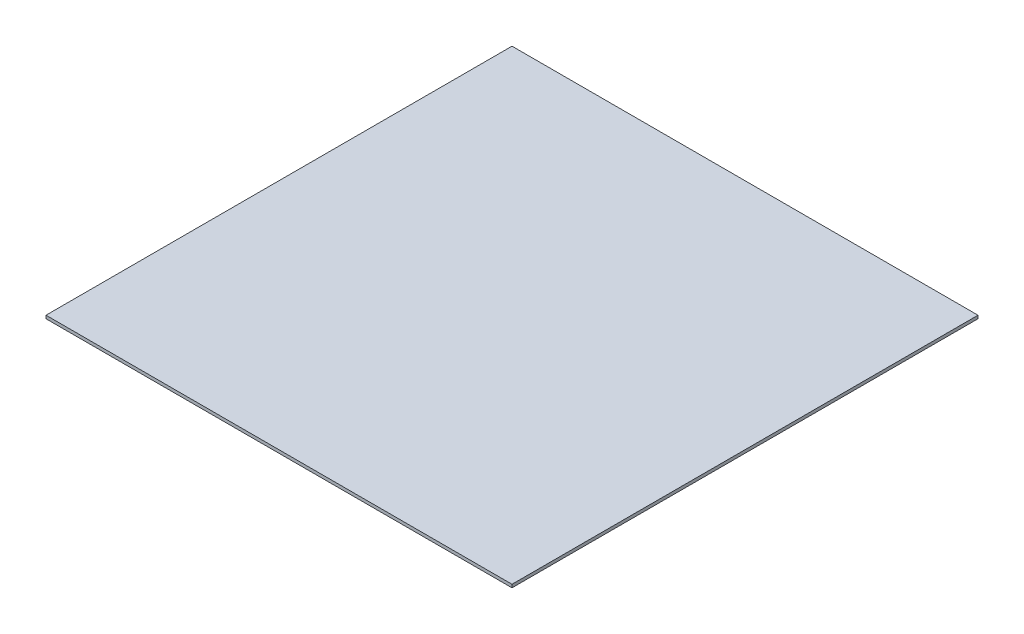
from build123d import *

# Parameters (mm, degrees)
SKETCH1_W           = 150
SKETCH1_H           = 150
BOSS_EXTRUDE1_DEPTH = 1


with BuildPart() as part:
    # Sketch1 → Boss-Extrude1 (new body)
    with BuildSketch(Plane(origin=(0, 92.411328497, 0), x_dir=(1, 0, 0), z_dir=(0, 1, 0))):
        with Locations((157.459777259, 243.327900012)):
            Rectangle(SKETCH1_W, SKETCH1_H)
    extrude(amount=BOSS_EXTRUDE1_DEPTH)


solid = part.part
